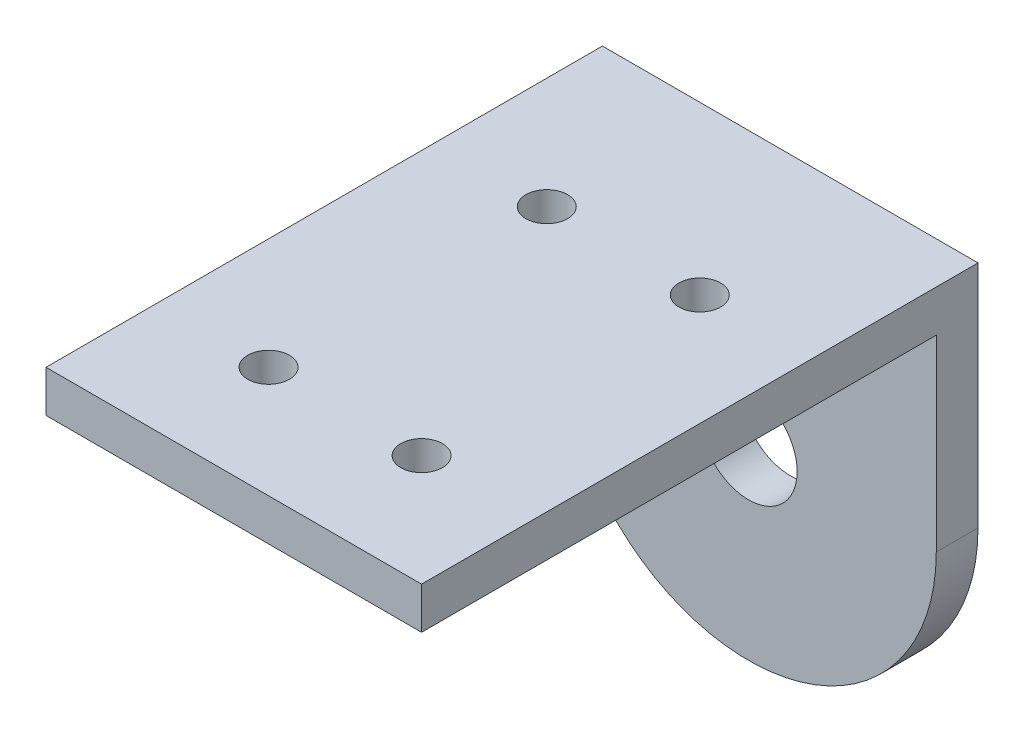
from build123d import *

# Parameters (mm, degrees)
MODEL_R             = 3.5
EXTRUDE_1_DEPTH     = 40
SKETCH_3_W          = 37
SKETCH_3_H          = 37
CUT_EXTRUDE_1_DEPTH = 40
SKETCH_4_R          = 1.5
CUT_EXTRUDE_2_DEPTH = 40


with BuildPart() as part:
    # Model → 凸台-拉伸1 (new body)
    with BuildSketch(Plane.XY):
        with BuildLine():
            Line((2619.766714505, 1592.826425633), (2619.766714505, 1609.326425633))
            Line((2619.766714505, 1609.326425633), (2592.766714505, 1609.326425633))
            Line((2592.766714505, 1609.326425633), (2592.766714505, 1592.826425633))
            ThreePointArc((2592.766714505, 1592.826425633), (2606.266714505, 1579.326425633), (2619.766714505, 1592.826425633))
        make_face()
        with Locations((2606.266714505, 1592.826425633)):
            Circle(MODEL_R, mode=Mode.SUBTRACT)
    extrude(amount=EXTRUDE_1_DEPTH)

    # 草图3 → 切除-拉伸1 (cut)
    with BuildSketch(Plane(origin=(2619.766714505, 0, 0), x_dir=(0, 0, -1), z_dir=(1, 0, 0))):
        with Locations((-21.5, 1587.826425633)):
            Rectangle(SKETCH_3_W, SKETCH_3_H)
    extrude(amount=-CUT_EXTRUDE_1_DEPTH, mode=Mode.SUBTRACT)

    # 草图4 → 切除-拉伸2 (cut)
    with BuildSketch(Plane(origin=(0, 1609.326425633, 0), x_dir=(1, 0, 0), z_dir=(0, 1, 0))):
        with Locations((2600.766714505, -32)):
            Circle(SKETCH_4_R)
        with Locations((2611.766714505, -32)):
            Circle(SKETCH_4_R)
        with Locations((2600.766714505, -12)):
            Circle(SKETCH_4_R)
        with Locations((2611.766714505, -12)):
            Circle(SKETCH_4_R)
    extrude(amount=-CUT_EXTRUDE_2_DEPTH, mode=Mode.SUBTRACT)


solid = part.part
